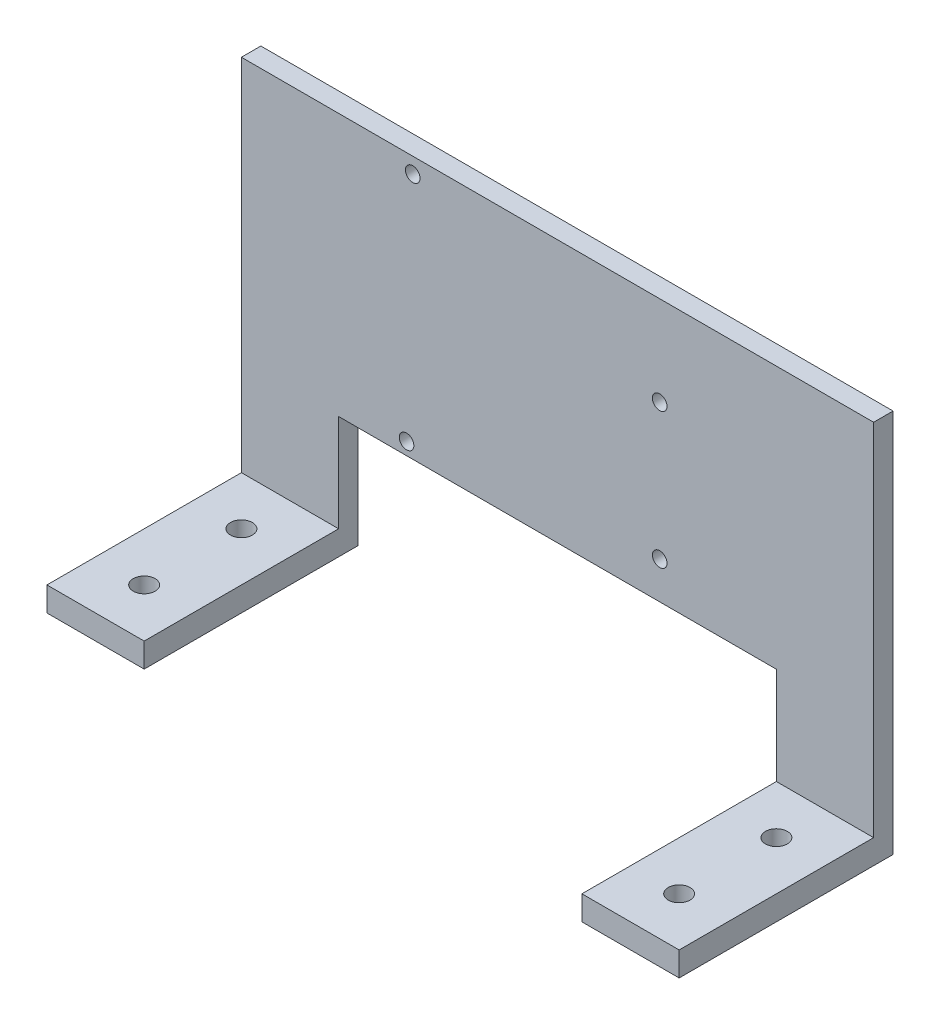
from build123d import *

# Parameters (mm, degrees)
SKETCH1_W                 = 20
SKETCH1_H                 = 44
SKETCH1_R                 = 2.25
BOSS_EXTRUDE1_DEPTH       = 5
BOSS_EXTRUDE1_2_DEPTH     = 5
SKETCH2_W                 = 130.04
SKETCH2_H                 = 4
BOSS_EXTRUDE2_DEPTH       = 74
BOSS_EXTRUDE2_DEPTH_BACK  = 5
SKETCH3_W                 = 90.04
SKETCH3_H                 = 25
CUT_EXTRUDE1_DEPTH        = 5
F_3_0MM_DOWEL_HOLE1_D     = 3
F_3_0MM_DOWEL_HOLE1_DEPTH = 5
F_3_0MM_DOWEL_HOLE1_TIP   = 0.901290929


with BuildPart() as part:
    # Sketch1 → Boss-Extrude1 (new body)
    with BuildSketch(Plane(origin=(0, 0, 0), x_dir=(1, 0, 0), z_dir=(0, 1, 0))):
        with Locations((0, 12)):
            Rectangle(SKETCH1_W, SKETCH1_H)
        Circle(SKETCH1_R, mode=Mode.SUBTRACT)
        with Locations((0, 20)):
            Circle(SKETCH1_R, mode=Mode.SUBTRACT)
    extrude(amount=BOSS_EXTRUDE1_DEPTH)



with BuildPart() as body_2:
    # Sketch1 → Boss-Extrude1 2 (new body)
    with BuildSketch(Plane(origin=(0, 0, 0), x_dir=(1, 0, 0), z_dir=(0, 1, 0))):
        with Locations((110.04, 12)):
            Rectangle(SKETCH1_W, SKETCH1_H)
        with Locations((110.04, 20)):
            Circle(SKETCH1_R, mode=Mode.SUBTRACT)
        with Locations((110.04, 0)):
            Circle(SKETCH1_R, mode=Mode.SUBTRACT)
    extrude(amount=BOSS_EXTRUDE1_2_DEPTH)


with BuildPart() as part_1:
    add(part.part)

    add(body_2.part)  # Boss-Extrude2 merges body 2
    # Sketch2 → Boss-Extrude2 (add, two sides)
    with BuildSketch(Plane(origin=(0, 5, 0), x_dir=(1, 0, 0), z_dir=(0, 1, 0))) as boss_extrude2_sk:
        with Locations((55.02, 32)):
            Rectangle(SKETCH2_W, SKETCH2_H)
    extrude(amount=BOSS_EXTRUDE2_DEPTH)
    extrude(boss_extrude2_sk.sketch, amount=-BOSS_EXTRUDE2_DEPTH_BACK)

    # Sketch3 → Cut-Extrude1 (cut)
    with BuildSketch(Plane.XY.offset(-30)):
        with Locations((55.02, 12.5)):
            Rectangle(SKETCH3_W, SKETCH3_H)
    extrude(amount=-CUT_EXTRUDE1_DEPTH, mode=Mode.SUBTRACT)

    # Ø3.0mm Dowel Hole1
    with Locations(Plane(origin=(55.834419791, -56, -30), x_dir=(1, 0, 0), z_dir=(0, 0, 1))):
        with Locations((-30.594419791, 131.8), (20.205580209, 116.56), (20.205580209, 88.62), (-31.864419791, 83.54)):
            Hole(F_3_0MM_DOWEL_HOLE1_D / 2, depth=F_3_0MM_DOWEL_HOLE1_DEPTH)
            with Locations((0, 0, -(F_3_0MM_DOWEL_HOLE1_DEPTH + F_3_0MM_DOWEL_HOLE1_TIP / 2))):  # 118° drill point
                Cone(0, F_3_0MM_DOWEL_HOLE1_D / 2, F_3_0MM_DOWEL_HOLE1_TIP, mode=Mode.SUBTRACT)


solid = part_1.part
